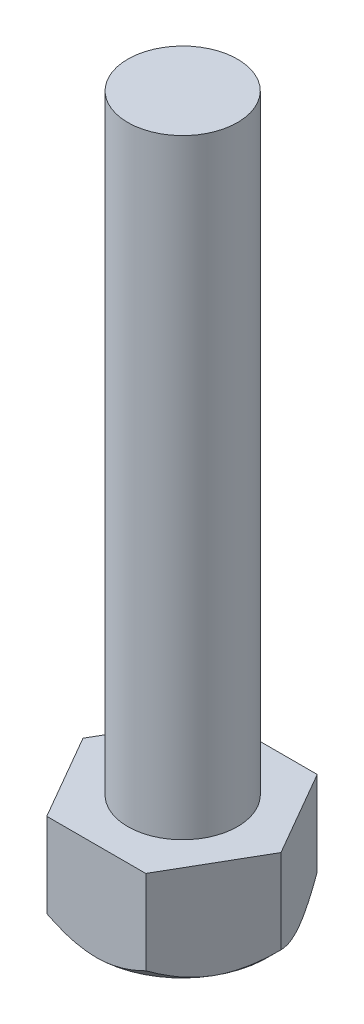
from build123d import *

# Parameters (mm, degrees)
SKETCH2_W           = 2.25
SKETCH2_H           = 25
BOSS_EXTRUDE1_DEPTH = 4
SKETCH4_OUTSIDE_W   = 76.3
SKETCH4_OUTSIDE_H   = 75.213
SKETCH4_OUTSIDE_R   = 3.514702834
CUT_EXTRUDE1_DEPTH  = 30
CUT_EXTRUDE1_TAPER  = 45


with BuildPart() as part:
    # Sketch2 → Revolve1 (revolve)
    with BuildSketch(Plane.XY):
        with Locations((1.125, 12.5)):
            Rectangle(SKETCH2_W, SKETCH2_H)
    revolve(axis=Axis((2.25, 25, 0), (0, -1, 0)))

    # Sketch3 → Boss-Extrude1 (add)
    with BuildSketch(Plane.XZ):
        Polygon((6.308429255, 0.02726243), (4.279214628, 3.541965265), (0.220785372, 3.541965265), (-1.808429255, 0.02726243), (0.220785372, -3.487440404), (4.279214628, -3.487440404), align=None)
    extrude(amount=BOSS_EXTRUDE1_DEPTH)

    # Sketch4 outside → Cut-Extrude1 (cut, through all)
    with BuildSketch(Plane(origin=(0, -4, 0), x_dir=(-1, 0, 0), z_dir=(0, -1, 0))):
        with Locations((-2.25, -0.0275)):
            Rectangle(SKETCH4_OUTSIDE_W, SKETCH4_OUTSIDE_H)
        with Locations((-2.25, -0.02726243)):
            Circle(SKETCH4_OUTSIDE_R, mode=Mode.SUBTRACT)
    extrude(amount=-CUT_EXTRUDE1_DEPTH, taper=CUT_EXTRUDE1_TAPER, mode=Mode.SUBTRACT)


solid = part.part
